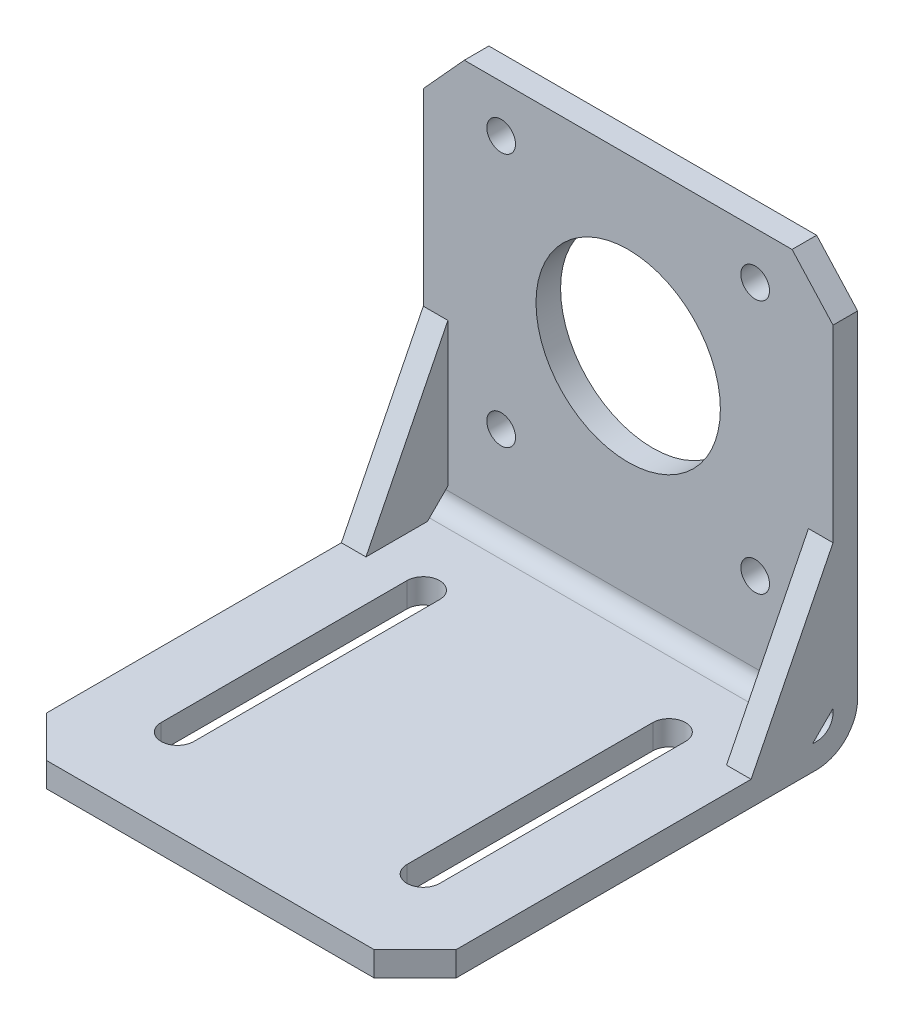
from build123d import *

# Parameters (mm, degrees)
ESQUISSE1_R        = 11.25
ESQUISSE1_R_2      = 1.75
BOSS_EXTRU_1_DEPTH = 3
BOSS_EXTRU_2_DEPTH = 3
CONG_1_R           = 2
CONG_2_R           = 5
BOSS_EXTRU_3_DEPTH = 3
BOSS_EXTRU_4_START = -50
BOSS_EXTRU_4_DEPTH = 3


with BuildPart() as part:
    # Esquisse1 → Boss.-Extru.1 (new body)
    with BuildSketch(Plane.XY):
        Polygon((-20, 51.5), (20, 51.5), (25, 46), (25, 0), (-25, 0), (-25, 46), align=None)
        with Locations((0, 30.25)):
            Circle(ESQUISSE1_R, mode=Mode.SUBTRACT)
        with Locations((15.5, 45.75)):
            Circle(ESQUISSE1_R_2, mode=Mode.SUBTRACT)
        with Locations((15.5, 14.75)):
            Circle(ESQUISSE1_R_2, mode=Mode.SUBTRACT)
        with Locations((-15.5, 14.75)):
            Circle(ESQUISSE1_R_2, mode=Mode.SUBTRACT)
        with Locations((-15.5, 45.75)):
            Circle(ESQUISSE1_R_2, mode=Mode.SUBTRACT)
    extrude(amount=BOSS_EXTRU_1_DEPTH)

    # Esquisse2 → Boss.-Extru.2 (add)
    with BuildSketch(Plane.XZ):
        Polygon((-20, 54), (20, 54), (25, 49), (25, 0), (-25, 0), (-25, 49), align=None)
        with BuildLine():
            Line((17, 43), (17, 13))
            ThreePointArc((17, 13), (15, 11), (13, 13))
            Line((13, 13), (13, 43))
            ThreePointArc((13, 43), (15, 45), (17, 43))
        make_face(mode=Mode.SUBTRACT)
        with BuildLine():
            Line((-17, 43), (-17, 13))
            ThreePointArc((-17, 13), (-15, 11), (-13, 13))
            Line((-13, 13), (-13, 43))
            ThreePointArc((-13, 43), (-15, 45), (-17, 43))
        make_face(mode=Mode.SUBTRACT)
    extrude(amount=-BOSS_EXTRU_2_DEPTH)

    # Congé1
    cong_1_edges = [part.edges().sort_by_distance(p)[0] for p in [
        (0, 3, 3),
    ]]
    fillet(cong_1_edges, radius=CONG_1_R)

    # Congé2
    cong_2_edges = [part.edges().sort_by_distance(p)[0] for p in [
        (0, 0, 0),
    ]]
    fillet(cong_2_edges, radius=CONG_2_R)

    # Esquisse3 → Boss.-Extru.3 (add)
    with BuildSketch(Plane.ZY.offset(25)):
        Polygon((13, 3), (3, 23), (3, 5.5), (5.5, 3), align=None)
    extrude(amount=-BOSS_EXTRU_3_DEPTH)

    # Esquisse3_3 → Boss.-Extru.4 (add)
    with BuildSketch(Plane.ZY.offset(25).offset(BOSS_EXTRU_4_START)):
        Polygon((13, 3), (3, 23), (3, 5.5), (5.5, 3), align=None)
    extrude(amount=BOSS_EXTRU_4_DEPTH)


solid = part.part
